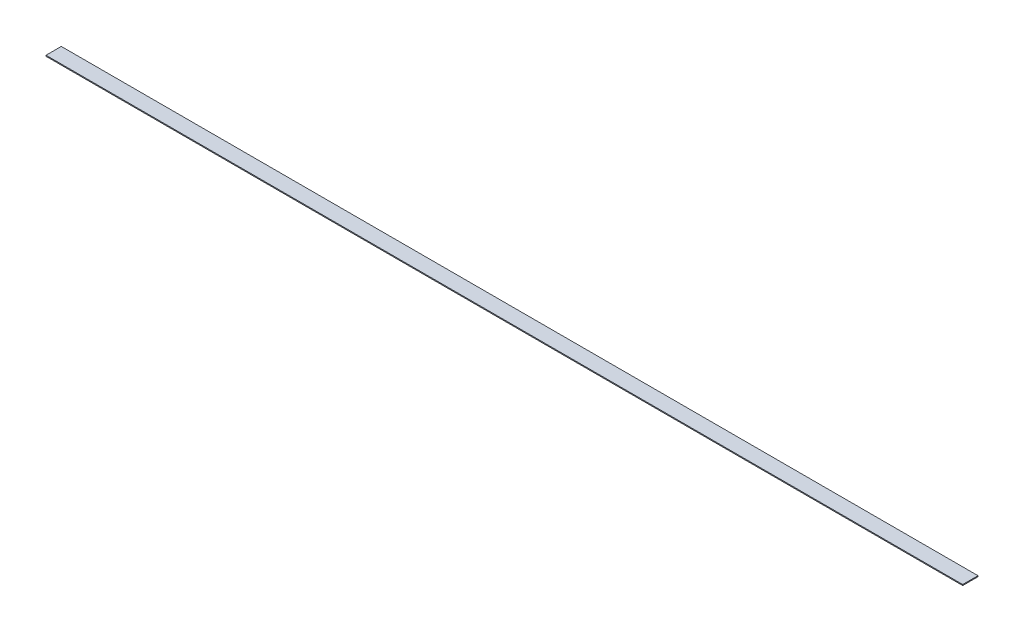
from build123d import *

# Parameters (mm, degrees)
SKETCH1_W           = 1524
SKETCH1_H           = 25.4
BOSS_EXTRUDE1_DEPTH = 1.5875


with BuildPart() as part:
    # Sketch1 → Boss-Extrude1 (new body)
    with BuildSketch(Plane(origin=(0, 0, 0), x_dir=(1, 0, 0), z_dir=(0, 1, 0))):
        with Locations((762, 12.7)):
            Rectangle(SKETCH1_W, SKETCH1_H)
    extrude(amount=BOSS_EXTRUDE1_DEPTH)


solid = part.part
